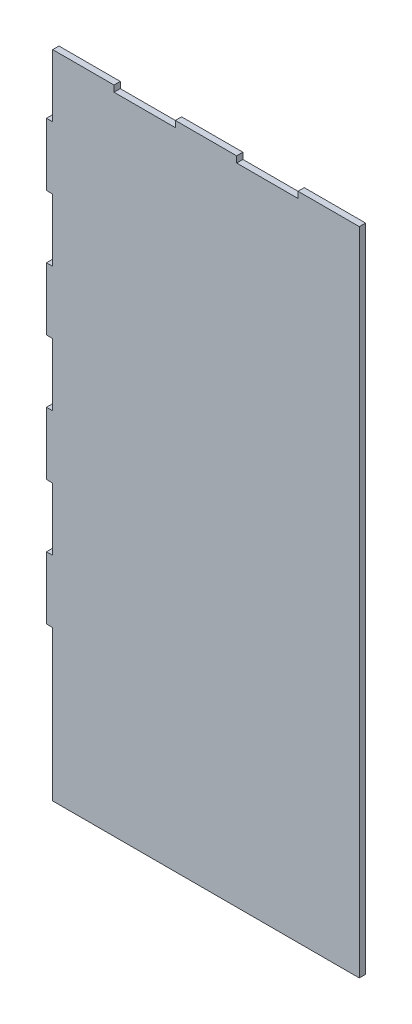
from build123d import *

# Parameters (mm, degrees)
BOSS_EXTRU_1_DEPTH = 5


with BuildPart() as part:
    # Esquisse1 → Boss.-Extru.1 (new body)
    with BuildSketch(Plane.XY):
        Polygon((0, 120), (0, 170), (5, 170), (5, 220), (0, 220), (0, 270), (5, 270), (5, 320), (0, 320), (0, 370), (5, 370), (5, 420), (0, 420), (0, 470), (5, 470), (5, 520), (54, 520), (54, 515), (103, 515), (103, 520), (152, 520), (152, 515), (201, 515), (201, 520), (250, 520), (250, 0), (5, 0), (5, 120), align=None)
    extrude(amount=BOSS_EXTRU_1_DEPTH)


solid = part.part
